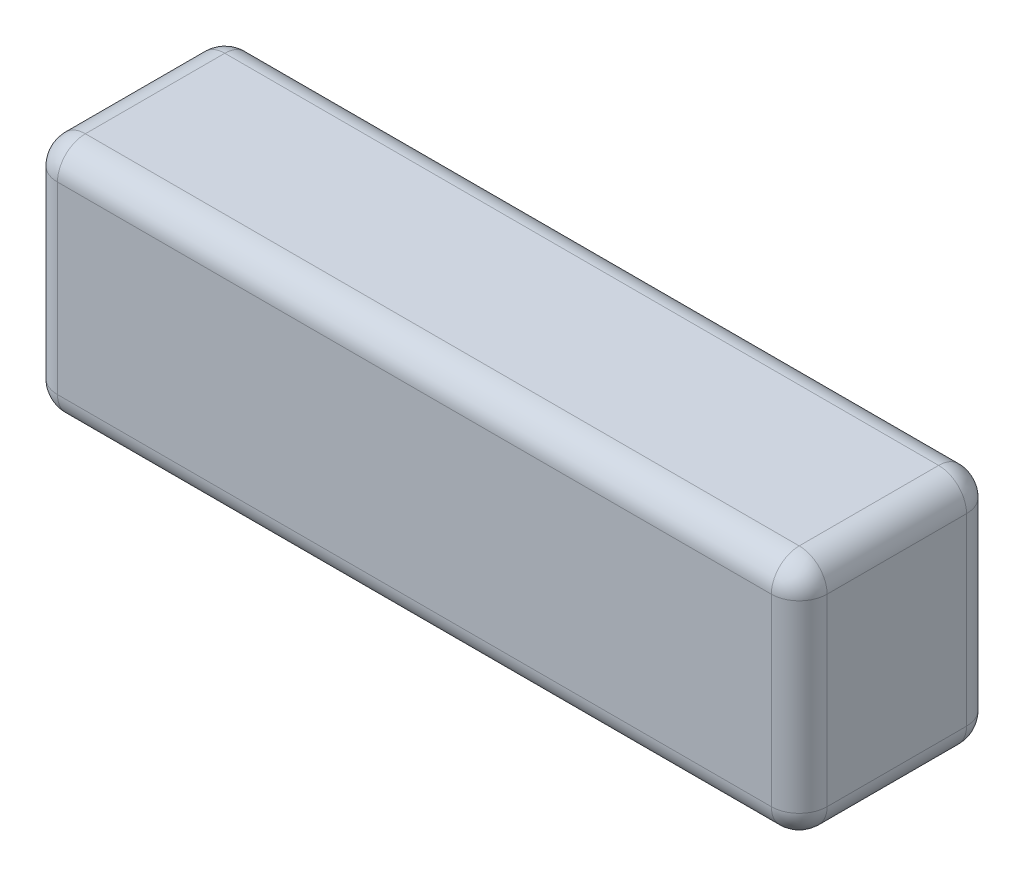
from build123d import *

# Parameters (mm, degrees)
SKETCH1_W           = 138
SKETCH1_H           = 43
BOSS_EXTRUDE1_DEPTH = 35
FILLET1_R           = 5


with BuildPart() as part:
    # Sketch1 → Boss-Extrude1 (new body)
    with BuildSketch(Plane.XY):
        Rectangle(SKETCH1_W, SKETCH1_H)
    extrude(amount=BOSS_EXTRUDE1_DEPTH)

    # Fillet1
    fillet1_edges = [part.edges().sort_by_distance(p)[0] for p in [
        (-69, 0, 35),
        (0, -21.5, 35),
        (69, 0, 35),
        (0, -21.5, 0),
        (-69, 0, 0),
        (0, 21.5, 0),
        (69, 0, 0),
        (69, -21.5, 17.5),
        (-69, -21.5, 17.5),
        (-69, 21.5, 17.5),
        (69, 21.5, 17.5),
        (0, 21.5, 35),
    ]]
    fillet(fillet1_edges, radius=FILLET1_R)


solid = part.part
